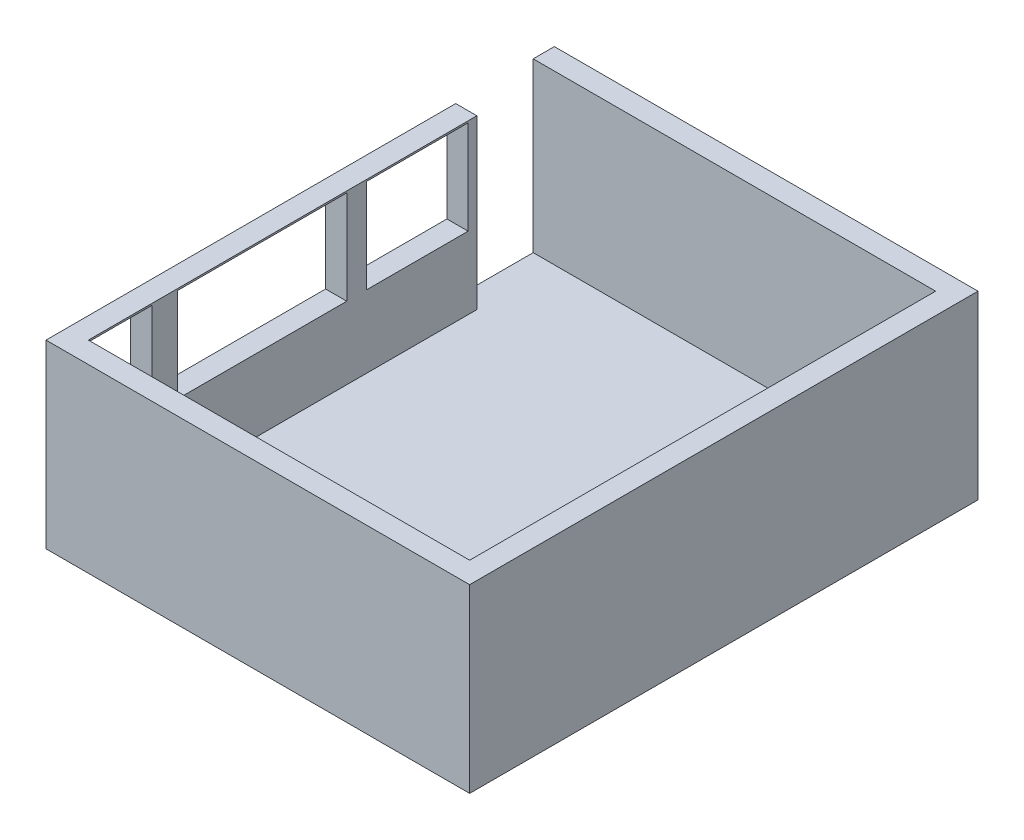
from build123d import *

# Parameters (mm, degrees)
SKETCH2_W           = 5000
SKETCH2_H           = 6000
BOSS_EXTRUDE1_DEPTH = 2133.6
SKETCH3_W           = 4500
SKETCH3_H           = 5500
WALL_DEPTH          = 1981.2
SKETCH5_W           = 1200
SKETCH5_H           = 1107.681828729
SKETCH5_W_2         = 750
SKETCH5_W_3         = 2000
DOOR_DEPTH          = 250
SKETCH4_W           = 914.4
SKETCH4_H           = 1981.2
WINDOWS_DEPTH       = 250


with BuildPart() as part:
    # Sketch2 → Boss-Extrude1 (new body)
    with BuildSketch(Plane(origin=(0, 0, 0), x_dir=(1, 0, 0), z_dir=(0, 1, 0))):
        with Locations((-2376.332337721, -2971.11164006)):
            Rectangle(SKETCH2_W, SKETCH2_H)
    extrude(amount=BOSS_EXTRUDE1_DEPTH)

    # Sketch3 → Wall (cut)
    with BuildSketch(Plane(origin=(0, 2133.6, 0), x_dir=(1, 0, 0), z_dir=(0, 1, 0))):
        with Locations((-2376.332337721, -2971.11164006)):
            Rectangle(SKETCH3_W, SKETCH3_H)
    extrude(amount=-WALL_DEPTH, mode=Mode.SUBTRACT)

    # Sketch5 → Door (cut)
    with BuildSketch(Plane(origin=(-4626.332337721, 0, 0), x_dir=(0, 0, -1), z_dir=(1, 0, 0))):
        with Locations((-1839.131416276, 1559.680914365)):
            Rectangle(SKETCH5_W, SKETCH5_H)
        with Locations((-5346.11164006, 1559.680914365)):
            Rectangle(SKETCH5_W_2, SKETCH5_H)
        with Locations((-3671.11164006, 1559.680914365)):
            Rectangle(SKETCH5_W_3, SKETCH5_H)
    extrude(amount=-DOOR_DEPTH, mode=Mode.SUBTRACT)

    # Sketch4 → Windows (cut)
    with BuildSketch(Plane.ZY.offset(4876.332337721)):
        with Locations((678.31164006, 1143)):
            Rectangle(SKETCH4_W, SKETCH4_H)
    extrude(amount=-WINDOWS_DEPTH, mode=Mode.SUBTRACT)


solid = part.part
